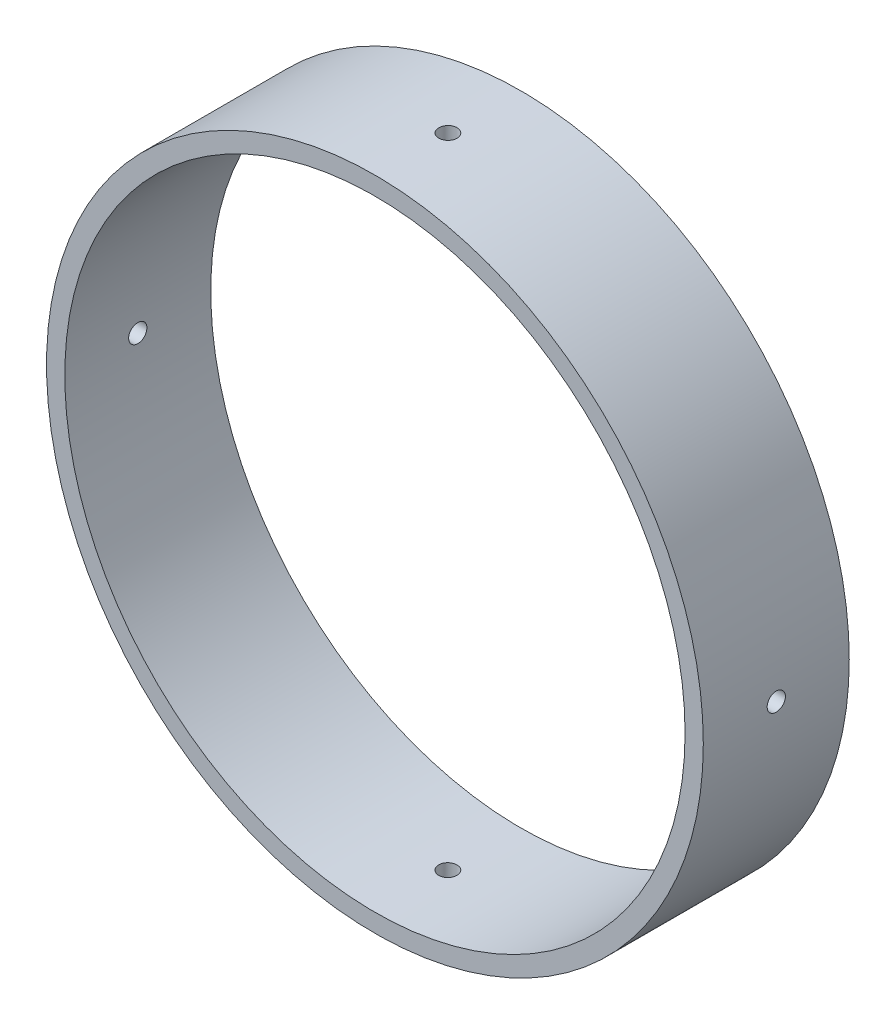
from build123d import *

# Parameters (mm, degrees)
SKETCH1_R           = 228.6
BOSS_EXTRUDE1_DEPTH = 101.6
SKETCH2_R           = 215.9
CUT_EXTRUDE1_DEPTH  = 102.6
SKETCH3_R           = 6.35
CUT_EXTRUDE2_DEPTH  = 458.2
SKETCH4_R           = 6.35
CUT_EXTRUDE3_DEPTH  = 458.2000001


with BuildPart() as part:
    # Sketch1 → Boss-Extrude1 (new body)
    with BuildSketch(Plane.XY):
        Circle(SKETCH1_R)
    extrude(amount=BOSS_EXTRUDE1_DEPTH)

    # Sketch2 → Cut-Extrude1 (cut, through all)
    with BuildSketch(Plane.XY.offset(101.6)):
        Circle(SKETCH2_R)
    extrude(amount=-CUT_EXTRUDE1_DEPTH, mode=Mode.SUBTRACT)

    # Sketch3 → Cut-Extrude2 (cut, through all)
    with BuildSketch(Plane(origin=(0, 228.6, 0), x_dir=(-1, 0, 0), z_dir=(0, 1, 0))):
        with Locations((0, 50.8)):
            Circle(SKETCH3_R)
    extrude(amount=-CUT_EXTRUDE2_DEPTH, mode=Mode.SUBTRACT)

    # Sketch4 → Cut-Extrude3 (cut, through all)
    with BuildSketch(Plane(origin=(228.6, 0, 0), x_dir=(0, 0, -1), z_dir=(1, 0, 0))):
        with Locations((-50.8, 0)):
            Circle(SKETCH4_R)
    extrude(amount=-CUT_EXTRUDE3_DEPTH, mode=Mode.SUBTRACT)


solid = part.part
